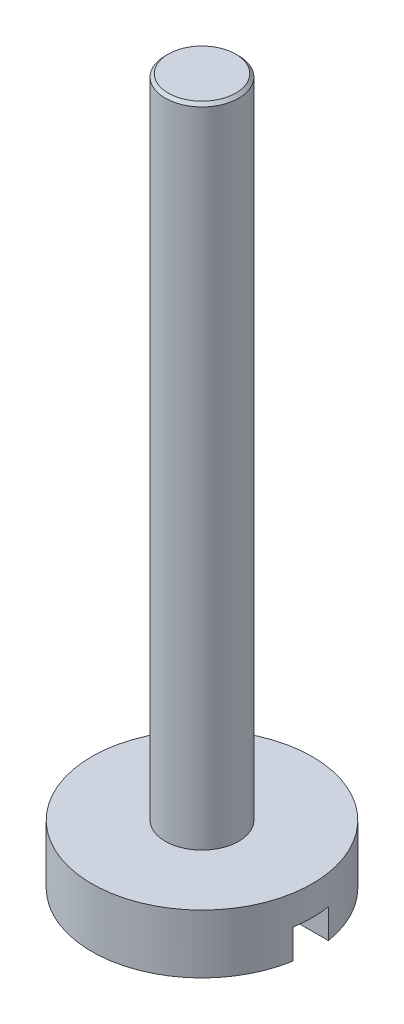
from build123d import *

# Parameters (mm, degrees)
SKETCH1_R           = 0.625
BOSS_EXTRUDE1_DEPTH = 11
SKETCH2_R           = 1.875
BOSS_EXTRUDE2_DEPTH = 1
SKETCH3_W           = 8.196351728
SKETCH3_H           = 0.6
CUT_EXTRUDE1_DEPTH  = 0.5
CHAMFER1_SIZE       = 0.05


with BuildPart() as part:
    # Sketch1 → Boss-Extrude1 (new body)
    with BuildSketch(Plane(origin=(0, 0, 0), x_dir=(1, 0, 0), z_dir=(0, 1, 0))):
        Circle(SKETCH1_R)
    extrude(amount=BOSS_EXTRUDE1_DEPTH)

    # Chamfer1
    chamfer1_edges = [part.edges().sort_by_distance(p)[0] for p in [
        (-0.625, 11, 0),
    ]]
    chamfer(chamfer1_edges, length=CHAMFER1_SIZE)


with BuildPart() as body_2:
    # Sketch2 → Boss-Extrude2 (new body)
    with BuildSketch(Plane.XZ):
        Circle(SKETCH2_R)
    extrude(amount=BOSS_EXTRUDE2_DEPTH)

    # Sketch3 → Cut-Extrude1 (cut)
    with BuildSketch(Plane.XZ.offset(1)):
        Rectangle(SKETCH3_W, SKETCH3_H)
    extrude(amount=-CUT_EXTRUDE1_DEPTH, mode=Mode.SUBTRACT)


solid = Compound([part.part, body_2.part])
